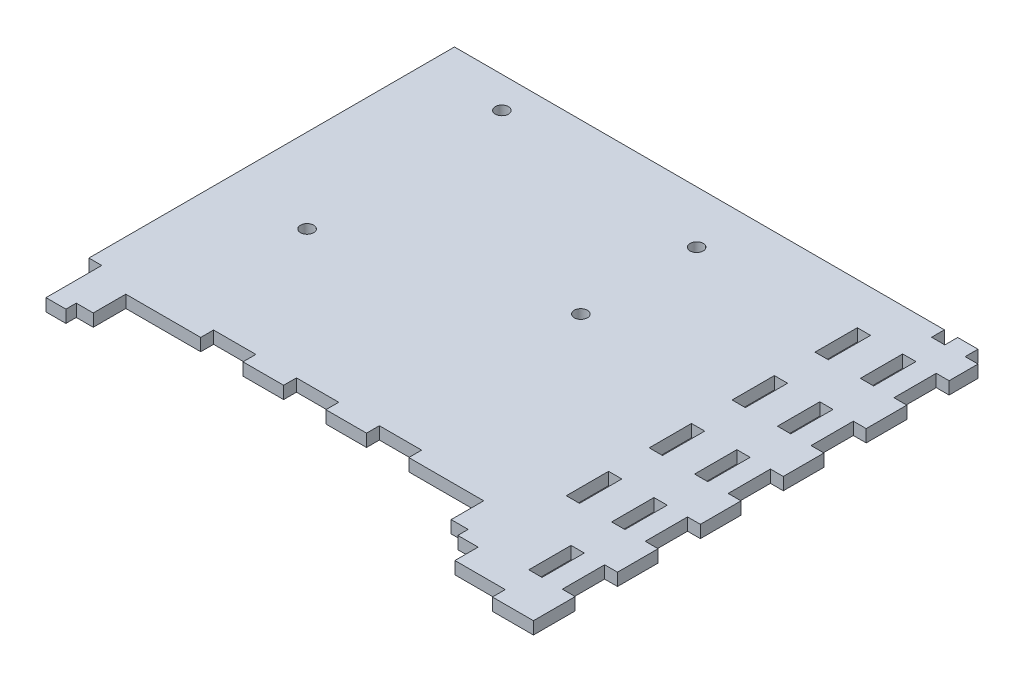
from build123d import *

# Parameters (mm, degrees)
BOSS_EXTRUDE1_DEPTH = 3
SKETCH2_R           = 1.5875
CUT_EXTRUDE1_DEPTH  = 4
SKETCH4_W           = 10.2
SKETCH4_H           = 3.2
SKETCH4_W_2         = 3.2
SKETCH4_H_2         = 10.2
SKETCH4_W_3         = 12.25
CUT_EXTRUDE2_DEPTH  = 4


with BuildPart() as part:
    # Sketch1 → Boss-Extrude1 (new body)
    with BuildSketch(Plane(origin=(0, 0, 0), x_dir=(1, 0, 0), z_dir=(0, 1, 0))):
        Polygon((-129.394434203, 8.1), (-117.394434203, 8.1), (-117.394434203, 19.05), (-31.05, 19.05), (-31.05, 8.1), (-22.05, 8.1), (-22.05, 0), (0, 0), (0, 110.344434203), (-129.394434203, 110.344434203), align=None)
    extrude(amount=-BOSS_EXTRUDE1_DEPTH)

    # Sketch2 → Cut-Extrude1 (cut, through all)
    with BuildSketch(Plane(origin=(0, 0, 0), x_dir=(1, 0, 0), z_dir=(0, 1, 0))):
        with Locations((-58.354434203, 97.724434203)):
            Circle(SKETCH2_R)
        with Locations((-58.354434203, 69.784434203)):
            Circle(SKETCH2_R)
        with Locations((-110.424434203, 102.804434203)):
            Circle(SKETCH2_R)
        with Locations((-109.154434203, 54.544434203)):
            Circle(SKETCH2_R)
    extrude(amount=-CUT_EXTRUDE1_DEPTH, mode=Mode.SUBTRACT)

    # Sketch4 → Cut-Extrude2 (cut, through all)
    with BuildSketch(Plane(origin=(0, 0, 0), x_dir=(1, 0, 0), z_dir=(0, 1, 0))):
        Polygon((-126.294434203, 22.15), (-129.494434203, 22.15), (-129.494434203, 8), (-117.294434203, 8), (-117.294434203, 11.2), (-121.494434203, 11.2), (-121.494434203, 8.7), (-126.294434203, 8.7), align=None)
        with Locations((-74.222217102, 20.55)):
            Rectangle(SKETCH4_W, SKETCH4_H)
        with Locations((-94.222217102, 20.55)):
            Rectangle(SKETCH4_W, SKETCH4_H)
        with Locations((-54.222217102, 20.55)):
            Rectangle(SKETCH4_W, SKETCH4_H)
        Polygon((-26.95, 8.7), (-22.05, 8.7), (-22.05, 8), (-31.15, 8), (-31.15, 11.2), (-26.95, 11.2), align=None)
        with Locations((-9.6, 35.172217102)):
            Rectangle(SKETCH4_W_2, SKETCH4_H_2)
        with Locations((-16.025, 1.5)):
            Rectangle(SKETCH4_W_3, SKETCH4_H)
        with Locations((-9.6, 15.172217102)):
            Rectangle(SKETCH4_W_2, SKETCH4_H_2)
        with Locations((-1.5, 15.172217102)):
            Rectangle(SKETCH4_W_2, SKETCH4_H_2)
        with Locations((-1.5, 35.172217102)):
            Rectangle(SKETCH4_W_2, SKETCH4_H_2)
        with Locations((-20.55, 35.172217102)):
            Rectangle(SKETCH4_W_2, SKETCH4_H_2)
        with Locations((-1.5, 55.172217102)):
            Rectangle(SKETCH4_W_2, SKETCH4_H_2)
        with Locations((-20.55, 55.172217102)):
            Rectangle(SKETCH4_W_2, SKETCH4_H_2)
        with Locations((-1.5, 75.172217102)):
            Rectangle(SKETCH4_W_2, SKETCH4_H_2)
        with Locations((-20.55, 75.172217102)):
            Rectangle(SKETCH4_W_2, SKETCH4_H_2)
        with Locations((-1.5, 95.172217102)):
            Rectangle(SKETCH4_W_2, SKETCH4_H_2)
        with Locations((-20.55, 95.172217102)):
            Rectangle(SKETCH4_W_2, SKETCH4_H_2)
        with Locations((-9.6, 108.844434203)):
            Rectangle(SKETCH4_W_2, SKETCH4_H)
        with Locations((-1.5, 108.844434203)):
            Rectangle(SKETCH4_W_2, SKETCH4_H)
        with Locations((-9.6, 95.172217102)):
            Rectangle(SKETCH4_W_2, SKETCH4_H_2)
        with Locations((-9.6, 75.172217102)):
            Rectangle(SKETCH4_W_2, SKETCH4_H_2)
        with Locations((-9.6, 55.172217102)):
            Rectangle(SKETCH4_W_2, SKETCH4_H_2)
    extrude(amount=-CUT_EXTRUDE2_DEPTH, mode=Mode.SUBTRACT)


solid = part.part
